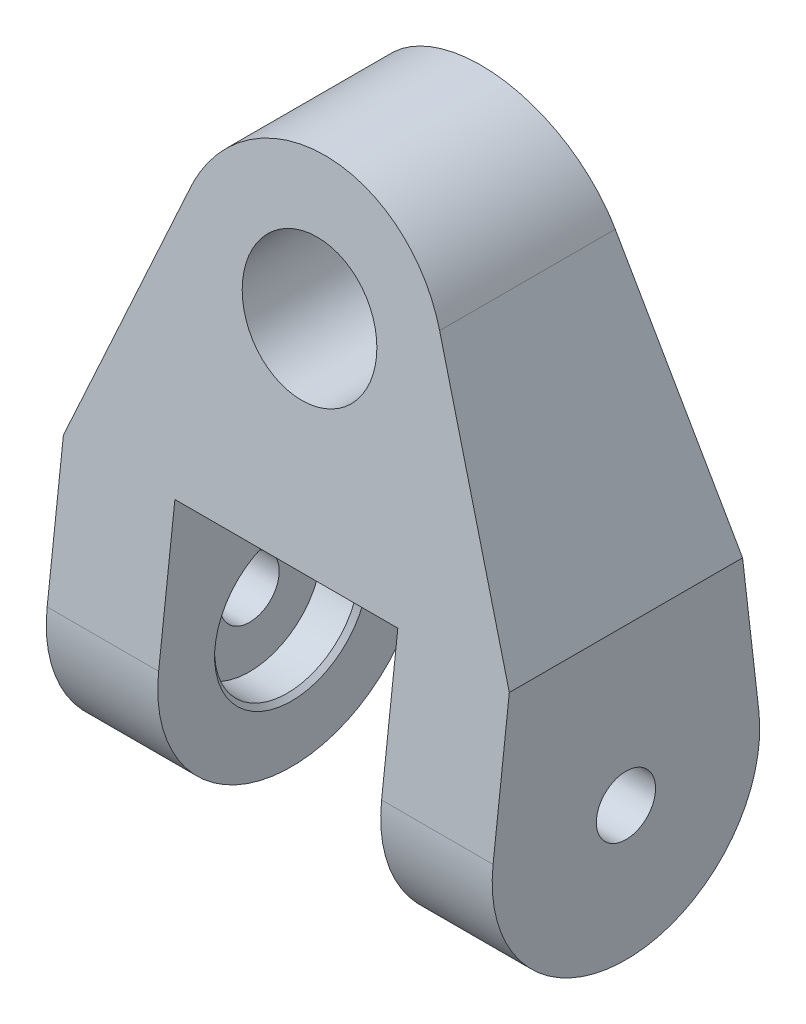
from build123d import *

# Parameters (mm, degrees)
SKETCH1_R               = 9.525
BOSS_EXTRUDE1_DEPTH     = 19.05
SKETCH2_OUTSIDE_W       = 63.24
SKETCH2_OUTSIDE_H       = 114.04
CUT_EXTRUDE1_DEPTH      = 32.75
CUT_EXTRUDE1_DEPTH_BACK = 32.75


with BuildPart() as part:
    # Sketch1 → Boss-Extrude1 (new body, symmetric)
    with BuildSketch(Plane.XY):
        with BuildLine():
            Line((17.721167904, 35.565186559), (31.75, 0))
            Line((31.75, 0), (31.75, -41.275))
            Line((31.75, -41.275), (15.875, -41.275))
            Line((15.875, -41.275), (15.875, 0))
            Line((15.875, 0), (-15.875, 0))
            Line((-15.875, 0), (-15.875, -41.275))
            Line((-15.875, -41.275), (-31.75, -41.275))
            Line((-31.75, -41.275), (-31.75, 0))
            Line((-31.75, 0), (-17.721167904, 35.565186559))
            ThreePointArc((-17.721167904, 35.565186559), (0, 47.625), (17.721167904, 35.565186559))
        make_face()
        with Locations((0, 28.575)):
            Circle(SKETCH1_R, mode=Mode.SUBTRACT)
    extrude(amount=BOSS_EXTRUDE1_DEPTH, both=True)

    # Sketch2 outside → Cut-Extrude1 (cut, two sides)
    with BuildSketch(Plane(origin=(0, 0, 0), x_dir=(0, 0, -1), z_dir=(1, 0, 0))) as cut_extrude1_sk:
        with Locations((0, 3.175)):
            Rectangle(SKETCH2_OUTSIDE_W, SKETCH2_OUTSIDE_H)
        with BuildLine():
            Line((18.924303972, -20.040230177), (11.1125, 47.625))
            Line((11.1125, 47.625), (-11.1125, 47.625))
            Line((-11.1125, 47.625), (-18.924303972, -20.040230177))
            ThreePointArc((-18.924303972, -20.040230177), (0, -41.275), (18.924303972, -20.040230177))
        make_face(mode=Mode.SUBTRACT)
    extrude(amount=CUT_EXTRUDE1_DEPTH, mode=Mode.SUBTRACT)
    extrude(cut_extrude1_sk.sketch, amount=-CUT_EXTRUDE1_DEPTH_BACK, mode=Mode.SUBTRACT)

    # Sketch6 → CBORE for 5/16 Hex Head Bolt2 (revolve, cut)
    with BuildSketch(Plane(origin=(-15.875, -22.225, 0), x_dir=(0, 0, -1), z_dir=(0, 1, 0))):
        Polygon((0, 0), (0, 15.875), (4.2164, 15.875), (4.2164, 5.969), (10.31875, 5.969), (10.31875, 0.635), (10.95375, 0), align=None)
    cbore_for_5_16_hex_head_bolt2 = revolve(axis=Axis((-9.525, -22.225, 0), (-1, 0, 0)), mode=Mode.SUBTRACT)

    # Mirror1: CBORE for 5/16 Hex Head Bolt2 across plane
    add(cbore_for_5_16_hex_head_bolt2.mirror(Plane(origin=(0, 0, 0), x_dir=(0, 0, 1), z_dir=(1, 0, 0))), mode=Mode.SUBTRACT)


solid = part.part
